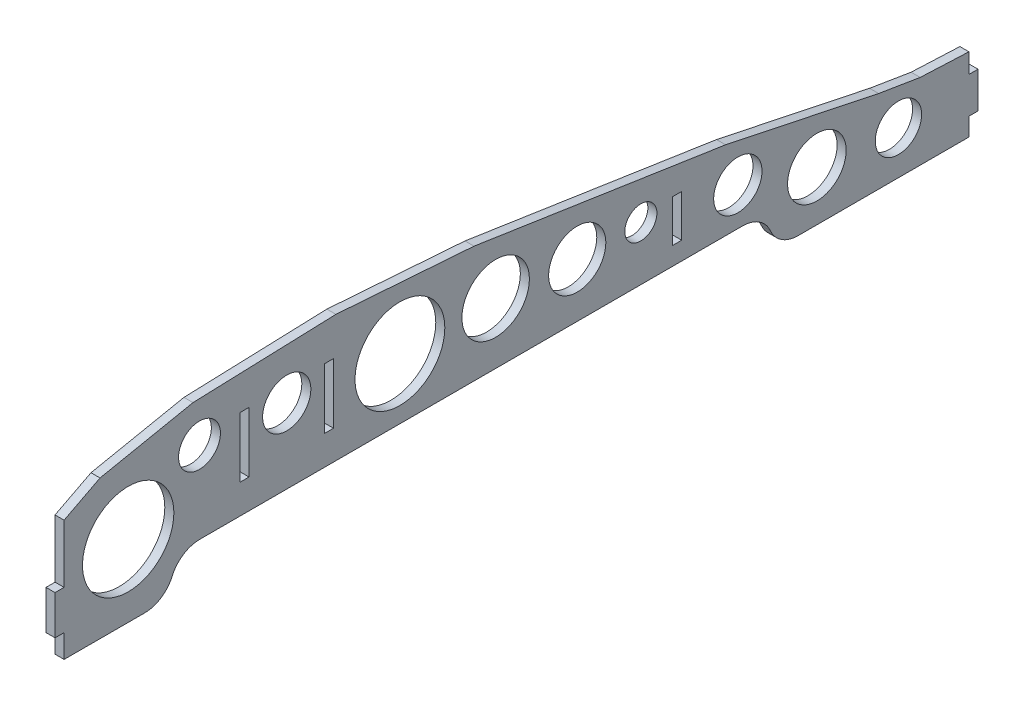
from build123d import *

# Parameters (mm, degrees)
BOSS_EXTRUDE1_DEPTH = 3
CUT_EXTRUDE1_DEPTH  = 3
FILLET1_R           = 10
SKETCH3_R           = 8
CUT_EXTRUDE2_DEPTH  = 3
SKETCH5_W           = 3
SKETCH5_H           = 13
SKETCH5_H_2         = 12
BOSS_EXTRUDE2_DEPTH = 3
SKETCH6_R           = 15.147681316
SKETCH6_R_2         = 6.940415837
SKETCH6_R_3         = 14.88620922
SKETCH6_R_4         = 11.185928508
SKETCH6_R_5         = 9.478125157
SKETCH6_R_6         = 5.324718802
SKETCH6_R_7         = 8.008616256
SKETCH6_R_8         = 9.712526273
SKETCH6_R_9         = 7.687216176
SKETCH6_W           = 3
SKETCH6_H           = 20
SKETCH6_H_2         = 14
CUT_EXTRUDE3_DEPTH  = 10


with BuildPart() as part:
    # Sketch1 → Boss-Extrude1 (new body)
    with BuildSketch(Plane(origin=(0, 0, 0), x_dir=(0, 0, -1), z_dir=(1, 0, 0))):
        Polygon((0, 0), (11.910798094, 6.158004928), (42.739414765, 12.383521095), (90.106781804, 14.033136775), (135.887385092, 10.713704644), (219.287488067, -1.876713431), (270.057015241, -12.532639482), (283.823146281, -14.792882614), (299.988096251, -15.517362165), (299.988096251, -40), (0, -40), align=None)
    extrude(amount=BOSS_EXTRUDE1_DEPTH)

    # Sketch2 → Cut-Extrude1 (cut)
    with BuildSketch(Plane(origin=(3, 0, 0), x_dir=(0, 0, -1), z_dir=(1, 0, 0))):
        with BuildLine():
            Line((35, -40), (35, -38))
            ThreePointArc((35, -38), (37.928932188, -30.928932188), (45, -28))
            Line((45, -28), (225, -28))
            ThreePointArc((225, -28), (232.071067812, -30.928932188), (235, -38))
            Line((235, -38), (235, -40))
            Line((235, -40), (35, -40))
        make_face()
    extrude(amount=-CUT_EXTRUDE1_DEPTH, mode=Mode.SUBTRACT)

    # Fillet1
    fillet1_edges = [part.edges().sort_by_distance(p)[0] for p in [
        (1.5, -40, -235),
        (1.5, -40, -35),
    ]]
    fillet(fillet1_edges, radius=FILLET1_R)

    # Sketch3 → Cut-Extrude2 (cut)
    with BuildSketch(Plane(origin=(3, 0, 0), x_dir=(0, 0, -1), z_dir=(1, 0, 0))):
        with Locations((73.81, -3.27)):
            Circle(SKETCH3_R)
    extrude(amount=-CUT_EXTRUDE2_DEPTH, mode=Mode.SUBTRACT)

    # Sketch5 → Boss-Extrude2 (add)
    with BuildSketch(Plane(origin=(3, 0, 0), x_dir=(0, 0, -1), z_dir=(1, 0, 0))):
        with Locations((-1.5, -25.8)):
            Rectangle(SKETCH5_W, SKETCH5_H)
        with Locations((301.488096251, -28.017362165)):
            Rectangle(SKETCH5_W, SKETCH5_H_2)
    extrude(amount=-BOSS_EXTRUDE2_DEPTH)

    # Sketch6 → Cut-Extrude3 (cut)
    with BuildSketch(Plane(origin=(3, 0, 0), x_dir=(0, 0, -1), z_dir=(1, 0, 0))):
        with Locations((21.242347481, -16.071768518)):
            Circle(SKETCH6_R)
        with Locations((44.884098964, -0.924087202)):
            Circle(SKETCH6_R_2)
        with Locations((111.33658962, -7.864503039)):
            Circle(SKETCH6_R_3)
        with Locations((143.071913682, -7.864503039)):
            Circle(SKETCH6_R_4)
        with Locations((170.121485199, -10.108083459)):
            Circle(SKETCH6_R_5)
        with Locations((191.207371657, -10.108083459)):
            Circle(SKETCH6_R_6)
        with Locations((223.368673224, -15.432802262)):
            Circle(SKETCH6_R_7)
        with Locations((249.566289732, -23.441418517)):
            Circle(SKETCH6_R_8)
        with Locations((276.615861249, -25.656262362)):
            Circle(SKETCH6_R_9)
        with Locations((59.81, -8.27)):
            Rectangle(SKETCH6_W, SKETCH6_H)
        with Locations((87.81, -8.27)):
            Rectangle(SKETCH6_W, SKETCH6_H)
        with Locations((203.245, -15)):
            Rectangle(SKETCH6_W, SKETCH6_H_2)
    extrude(amount=-CUT_EXTRUDE3_DEPTH, mode=Mode.SUBTRACT)


solid = part.part
